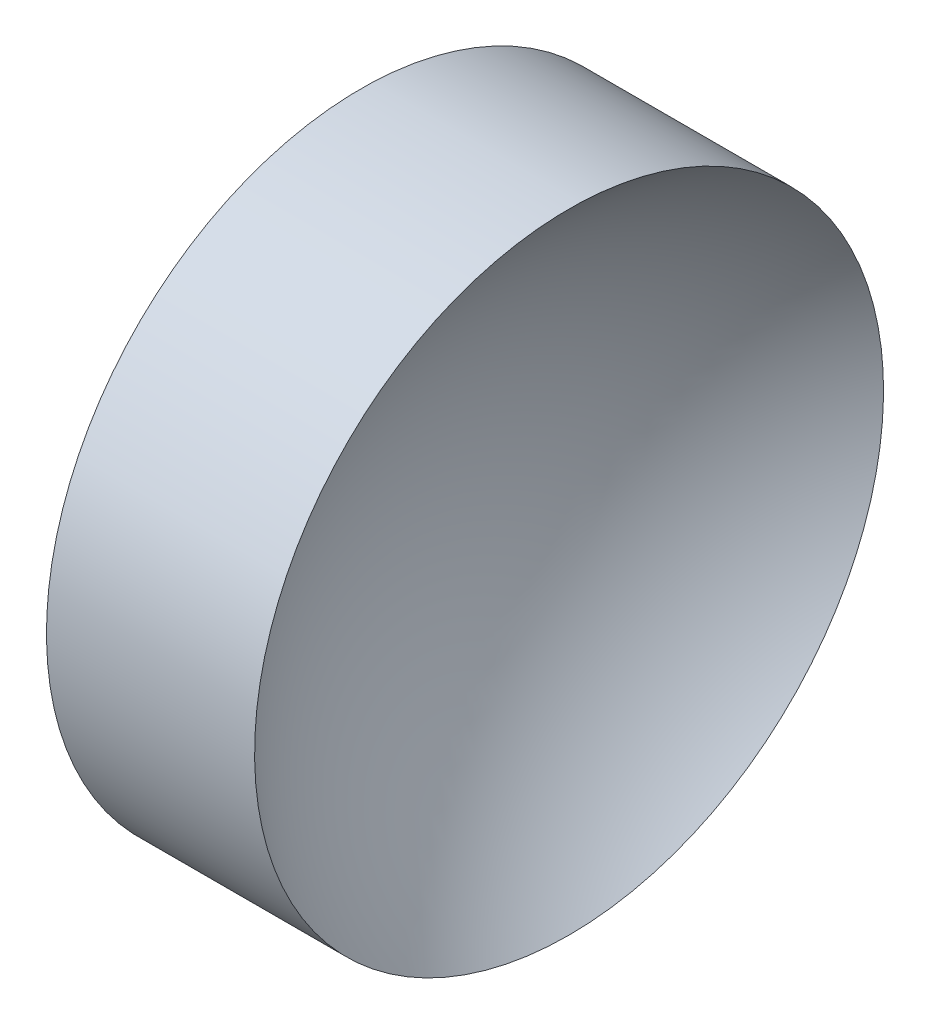
from build123d import *


with BuildPart() as part:
    # 草图1 → 旋转1 (revolve)
    with BuildSketch(Plane.XY, mode=Mode.PRIVATE) as revolve_1_sk:
        with BuildLine():
            Line((44.854422626, 26.062252183), (44.854422626, 34.062252183))
            Line((44.854422626, 34.062252183), (50.149217962, 34.062252183))
            ThreePointArc((50.149217962, 34.062252183), (47.351214063, 30.489454224), (46.354422626, 26.062252183))
            Line((46.354422626, 26.062252183), (44.854422626, 26.062252183))
        make_face()
    revolve(revolve_1_sk.sketch.rotate(Axis((43.011950236, 26.062252183, 0), (1, 0, 0)), 180), axis=Axis((43.011950236, 26.062252183, 0), (1, 0, 0)))  # turned: the seam where the file's is


solid = part.part
